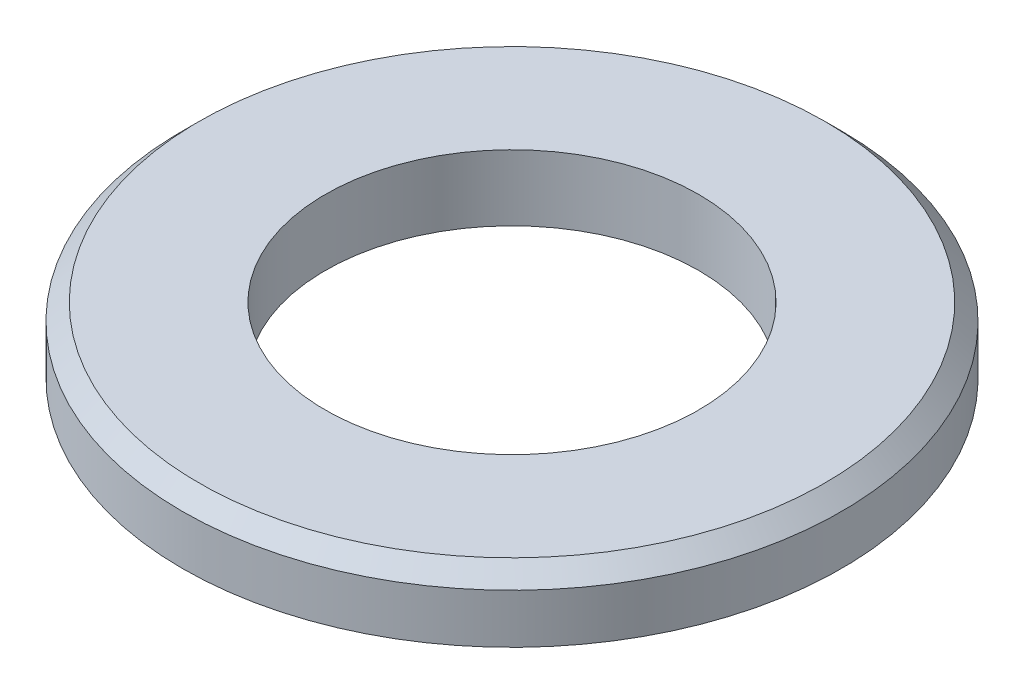
from build123d import *


with BuildPart() as part:
    # 草图1 → Revolve 484 (revolve)
    with BuildSketch(Plane.XY):
        Polygon((-14.25, 11.644507042), (-15, 10.894507042), (-15, 8.644507042), (-8.5, 8.644507042), (-8.5, 11.644507042), align=None)
    revolve(axis=Axis((0, 0, 0), (0, 1, 0)))


solid = part.part
